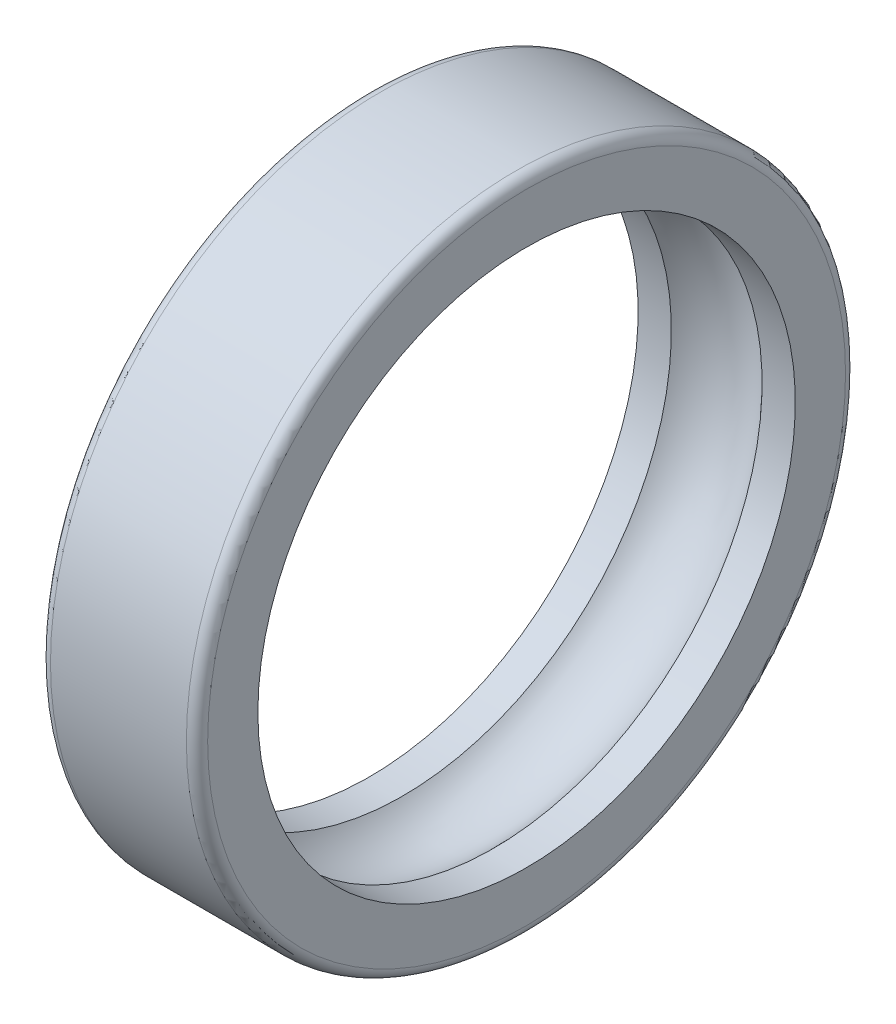
from build123d import *

# Parameters (mm, degrees)
FILLET1_R = 2.1


with BuildPart() as part:
    # Sketch1 → Revolve1 (revolve)
    with BuildSketch(Plane.XY):
        with BuildLine():
            Line((-15.5, 65), (15.5, 65))
            Line((15.5, 65), (15.5, 53))
            Line((15.5, 53), (8.94427191, 53))
            ThreePointArc((8.94427191, 53), (0, 57), (-8.94427191, 53))
            Line((-8.94427191, 53), (-15.5, 53))
            Line((-15.5, 53), (-15.5, 65))
        make_face()
    revolve(axis=Axis((-41.527742449, 0, 0), (1, 0, 0)))

    # Fillet1
    fillet1_edges = [part.edges().sort_by_distance(p)[0] for p in [
        (-15.5, -65, 0),
        (15.5, -65, 0),
    ]]
    fillet(fillet1_edges, radius=FILLET1_R)


solid = part.part
